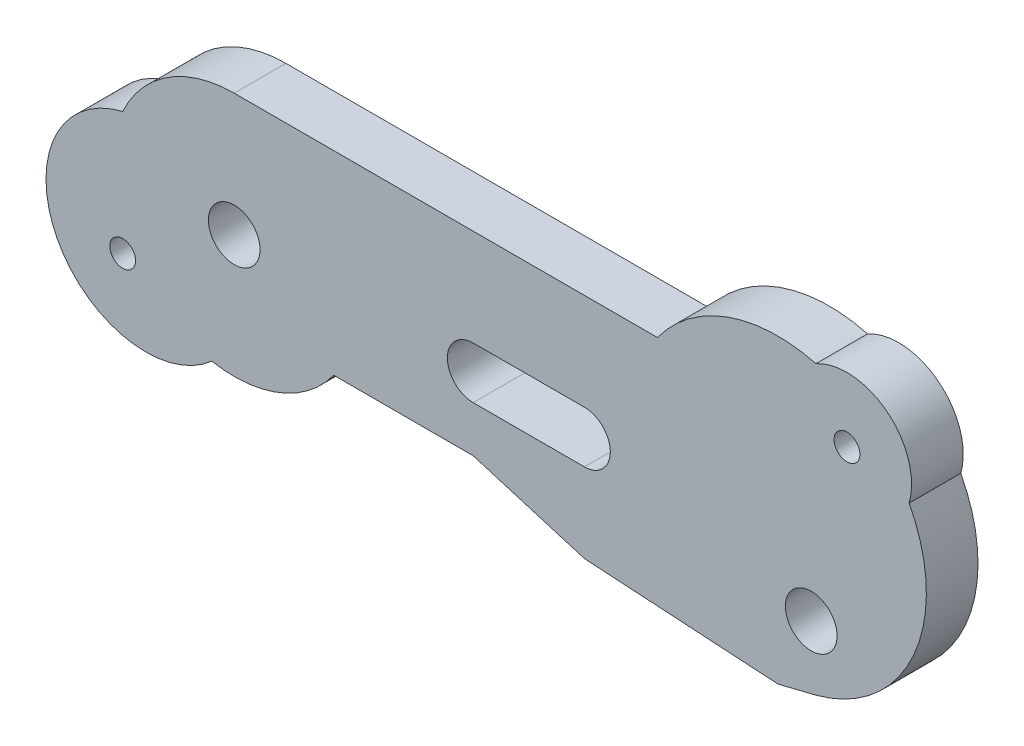
from build123d import *

# Parameters (mm, degrees)
SKETCH1_R           = 1
SKETCH1_R_2         = 2
BOSS_EXTRUDE1_DEPTH = 4


with BuildPart() as part:
    # Sketch1 → Boss-Extrude1 (new body)
    with BuildSketch(Plane.XY):
        with BuildLine():
            Line((32.768661414, 9.5), (0, 9.5))
            ThreePointArc((0, 9.5), (-5.132216198, 7.994395343), (-8.637676899, 3.954811978))
            ThreePointArc((-8.637676899, 3.954811978), (-13.707021242, -7.117107183), (-1.734430481, -9.340329272))
            ThreePointArc((-1.734430481, -9.340329272), (3.531285703, -8.819298231), (7.70145267, -5.562160262))
            Line((7.70145267, -5.562160262), (18.50145267, -5.562160262))
            Line((18.50145267, -5.562160262), (27.120384516, -8.153301675))
            Line((27.120384516, -8.153301675), (42.092126283, -9.073599712))
            Line((42.092126283, -9.073599712), (44.676644991, -8.438049901))
            Line((44.676644991, -8.438049901), (44.999262596, -8.358716152))
            ThreePointArc((44.999262596, -8.358716152), (52.618268655, -1.863685843), (52.259320622, 8.141604176))
            ThreePointArc((52.259320622, 8.141604176), (50.560022951, 13.41298626), (45.041503714, 13.883121423))
            ThreePointArc((45.041503714, 13.883121423), (38.224286315, 13.597806101), (32.768661414, 9.5))
        make_face()
        with Locations((-8.637676899, -5.562160262)):
            Circle(SKETCH1_R, mode=Mode.SUBTRACT)
        Circle(SKETCH1_R_2, mode=Mode.SUBTRACT)
        with BuildLine():
            ThreePointArc((18.50145267, -2), (16.50145267, 0), (18.50145267, 2))
            Line((18.50145267, 2), (27.120384516, 2))
            ThreePointArc((27.120384516, 2), (29.120384516, 0), (27.120384516, -2))
            Line((27.120384516, -2), (18.50145267, -2))
        make_face(mode=Mode.SUBTRACT)
        with Locations((44.676644991, -3.558553592)):
            Circle(SKETCH1_R_2, mode=Mode.SUBTRACT)
        with Locations((47.447381223, 9.5)):
            Circle(SKETCH1_R, mode=Mode.SUBTRACT)
    extrude(amount=BOSS_EXTRUDE1_DEPTH)


solid = part.part
